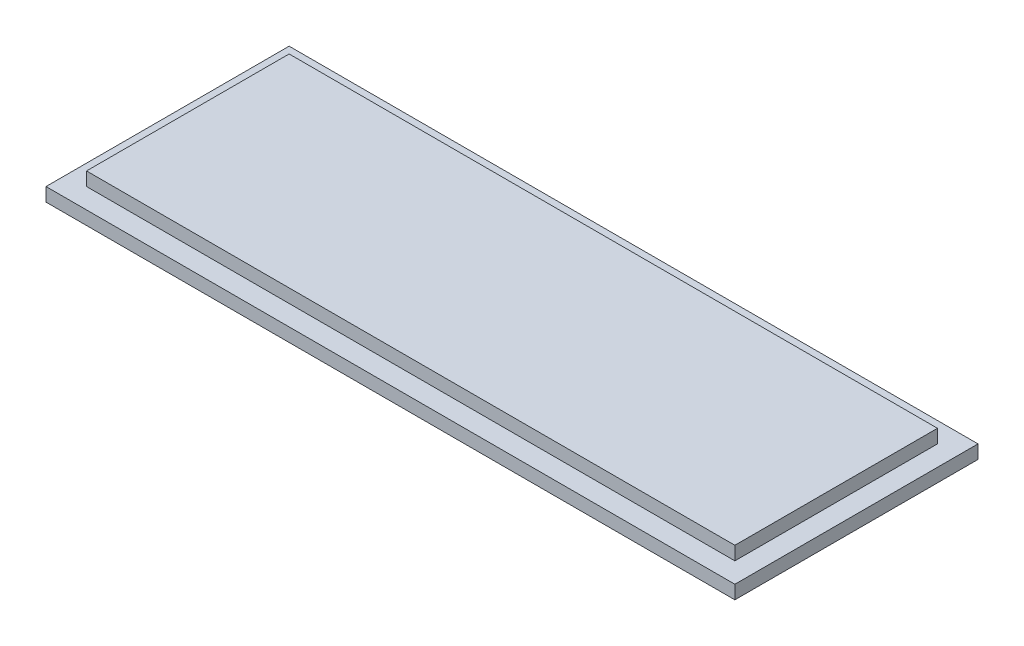
from build123d import *

# Parameters (mm, degrees)
SKETCH_2_W      = 51
SKETCH_2_H      = 18
EXTRUDE_1_DEPTH = 1
SKETCH_3_W      = 48
SKETCH_3_H      = 15
EXTRUDE_2_DEPTH = 1


with BuildPart() as part:
    # 草图2 → 凸台-拉伸1 (new body)
    with BuildSketch(Plane(origin=(0, 0, 0), x_dir=(1, 0, 0), z_dir=(0, 1, 0))):
        Rectangle(SKETCH_2_W, SKETCH_2_H)
    extrude(amount=EXTRUDE_1_DEPTH)

    # 草图3 → 凸台-拉伸2 (add)
    with BuildSketch(Plane(origin=(0, 1, 0), x_dir=(1, 0, 0), z_dir=(0, 1, 0))):
        Rectangle(SKETCH_3_W, SKETCH_3_H)
    extrude(amount=EXTRUDE_2_DEPTH)


solid = part.part
